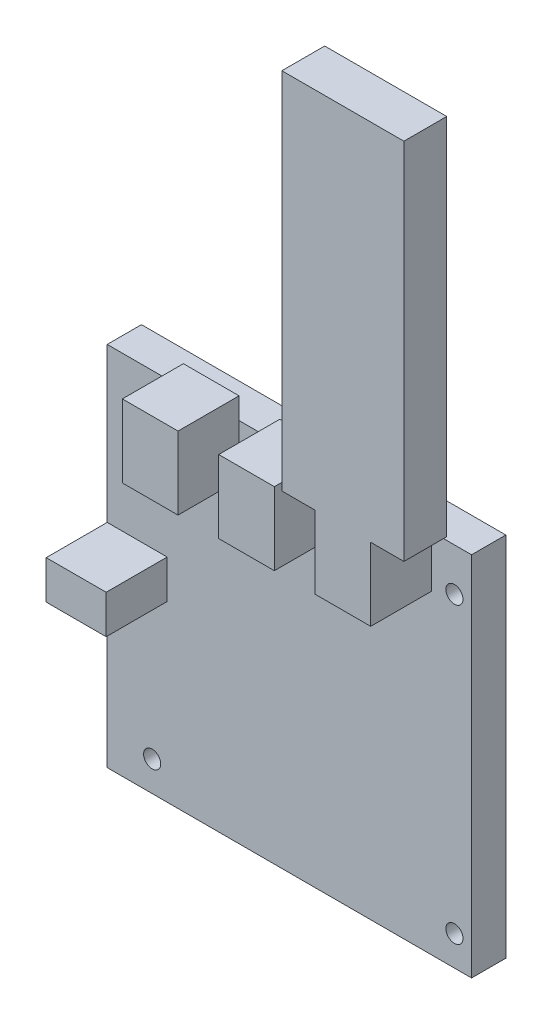
from build123d import *

# Parameters (mm, degrees)
SKETCH1_W           = 85.09
SKETCH1_H           = 85.6
SKETCH1_R           = 2
BOSS_EXTRUDE1_DEPTH = 8
SKETCH2_W           = 13
SKETCH2_H           = 17
SKETCH2_W_2         = 14
SKETCH2_H_2         = 9
BOSS_EXTRUDE2_DEPTH = 14.25
SKETCH3_R           = 2.5
CUT_EXTRUDE1_DEPTH  = 3
SKETCH4_W           = 28.5
SKETCH4_H           = 10
BOSS_EXTRUDE3_DEPTH = 85


with BuildPart() as part:
    # Sketch1 → Boss-Extrude1 (new body)
    with BuildSketch(Plane.XY):
        Rectangle(SKETCH1_W, SKETCH1_H)
        with Locations((-32.045, 32.8)):
            Circle(SKETCH1_R, mode=Mode.SUBTRACT)
        with Locations((38.545, 32.8)):
            Circle(SKETCH1_R, mode=Mode.SUBTRACT)
        with Locations((38.545, -35.8)):
            Circle(SKETCH1_R, mode=Mode.SUBTRACT)
        with Locations((-32.045, -35.8)):
            Circle(SKETCH1_R, mode=Mode.SUBTRACT)
    extrude(amount=BOSS_EXTRUDE1_DEPTH)

    # Sketch2 → Boss-Extrude2 (add)
    with BuildSketch(Plane.XY.offset(8)):
        with Locations((26.745, 39.3)):
            Rectangle(SKETCH2_W, SKETCH2_H)
        with Locations((4.245, 39.3)):
            Rectangle(SKETCH2_W, SKETCH2_H)
        with Locations((-18.255, 39.3)):
            Rectangle(SKETCH2_W, SKETCH2_H)
        with Locations((-35.545, 2.3)):
            Rectangle(SKETCH2_W_2, SKETCH2_H_2)
    extrude(amount=BOSS_EXTRUDE2_DEPTH)

    # Sketch3 → Cut-Extrude1 (cut)
    with BuildSketch(Plane.ZY.offset(42.545)):
        with Locations((16.25, 2.3)):
            Circle(SKETCH3_R)
    extrude(amount=-CUT_EXTRUDE1_DEPTH, mode=Mode.SUBTRACT)

    # Sketch4 → Boss-Extrude3 (add)
    with BuildSketch(Plane(origin=(0, 47.8, 0), x_dir=(1, 0, 0), z_dir=(0, 1, 0))):
        with Locations((26.745, -17.25)):
            Rectangle(SKETCH4_W, SKETCH4_H)
    extrude(amount=BOSS_EXTRUDE3_DEPTH)


solid = part.part
